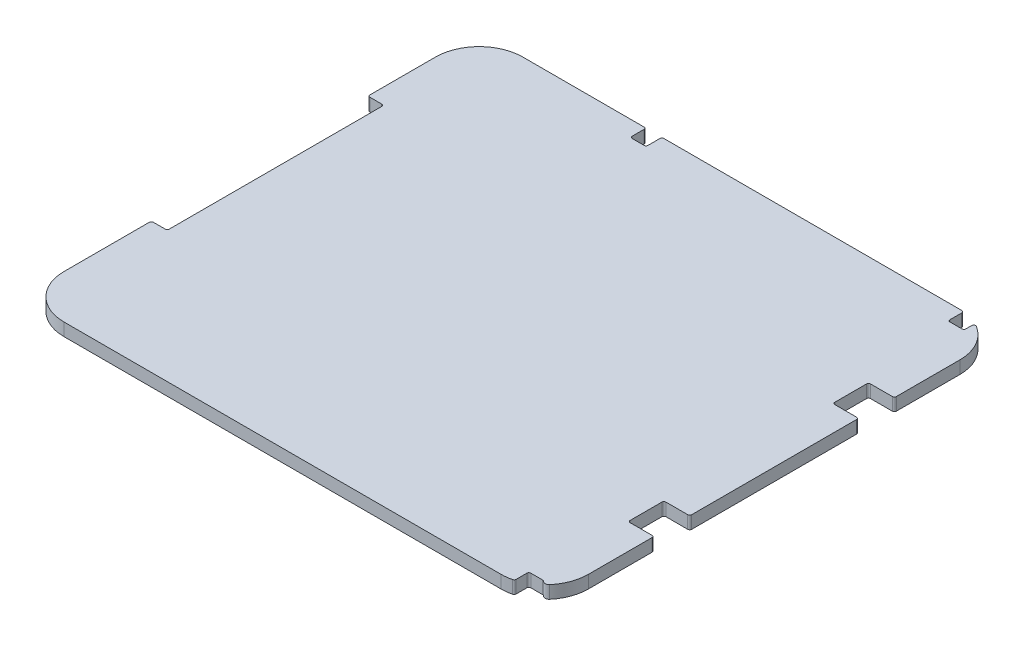
from build123d import *

# Parameters (mm, degrees)
ESQUISSE1_W                  = 66
ESQUISSE1_H                  = 57.75
BOSS_EXTRU_1_DEPTH           = 0.8
CONG_1_R                     = 5.5
ESQUISSE3_W                  = 4
ESQUISSE3_H                  = 27.25
ESQUISSE3_W_2                = 6.5
ESQUISSE3_H_2                = 4.5
ESQUISSE3_W_3                = 2
ESQUISSE3_H_3                = 4
ENL_V_MAT_EXTRU_1_DEPTH      = 1.8
ENL_V_MAT_EXTRU_1_DEPTH_BACK = 1.8
CONG_2_R                     = 0.25
CONG_3_R                     = 0.5


with BuildPart() as part:
    # Esquisse1 → Boss.-Extru.1 (new body, symmetric)
    with BuildSketch(Plane(origin=(0, 0, 0), x_dir=(1, 0, 0), z_dir=(0, 1, 0))):
        Rectangle(ESQUISSE1_W, ESQUISSE1_H)
    extrude(amount=BOSS_EXTRU_1_DEPTH, both=True)

    # Congé1
    cong_1_edges = [part.edges().sort_by_distance(p)[0] for p in [
        (33, 0, 28.875),
        (-33, 0, 28.875),
        (-33, 0, -28.875),
        (33, 0, -28.875),
    ]]
    fillet(cong_1_edges, radius=CONG_1_R)

    # Esquisse3 → Enlèv. mat.-Extru.1 (cut, two sides)
    with BuildSketch(Plane(origin=(0, 0, 0), x_dir=(1, 0, 0), z_dir=(0, 1, 0))) as enl_v_mat_extru_1_sk:
        with Locations((-33, 1.245)):
            Rectangle(ESQUISSE3_W, ESQUISSE3_H)
        with Locations((33, -12.875)):
            Rectangle(ESQUISSE3_W_2, ESQUISSE3_H_2)
        with Locations((-11, 28.875)):
            Rectangle(ESQUISSE3_W_3, ESQUISSE3_H_3)
        with Locations((29, 28.875)):
            Rectangle(ESQUISSE3_W_3, ESQUISSE3_H_3)
        with Locations((30, -28.875)):
            Rectangle(ESQUISSE3_W_3, ESQUISSE3_H_3)
        with Locations((33, 12.875)):
            Rectangle(ESQUISSE3_W_2, ESQUISSE3_H_2)
    extrude(amount=ENL_V_MAT_EXTRU_1_DEPTH, mode=Mode.SUBTRACT)
    extrude(enl_v_mat_extru_1_sk.sketch, amount=-ENL_V_MAT_EXTRU_1_DEPTH_BACK, mode=Mode.SUBTRACT)

    # Congé2
    cong_2_edges = [part.edges().sort_by_distance(p)[0] for p in [
        (30, 0, -26.875),
        (28, 0, -26.875),
        (33, 0, 10.625),
        (29.75, 0, 10.625),
        (33, 0, 15.125),
        (29.75, 0, 15.125),
        (29, 0, 28.666502622),
        (28, 0, -28.852225575),
        (30, 0, -28.273979486),
        (-33, 0, 12.38),
        (-31, 0, 12.38),
        (-33, 0, -14.87),
        (-31, 0, -14.87),
        (33, 0, -10.625),
        (33, 0, -15.125),
        (29.75, 0, -15.125),
        (29.75, 0, -10.625),
        (-10, 0, -28.875),
        (-12, 0, -28.875),
        (-12, 0, -26.875),
        (-10, 0, -26.875),
        (31, 0, 26.875),
        (29, 0, 26.875),
    ]]
    fillet(cong_2_edges, radius=CONG_2_R)

    # Congé3
    cong_3_edges = [part.edges().sort_by_distance(p)[0] for p in [
        (31, 0, 27.617640687),
    ]]
    fillet(cong_3_edges, radius=CONG_3_R)


solid = part.part
